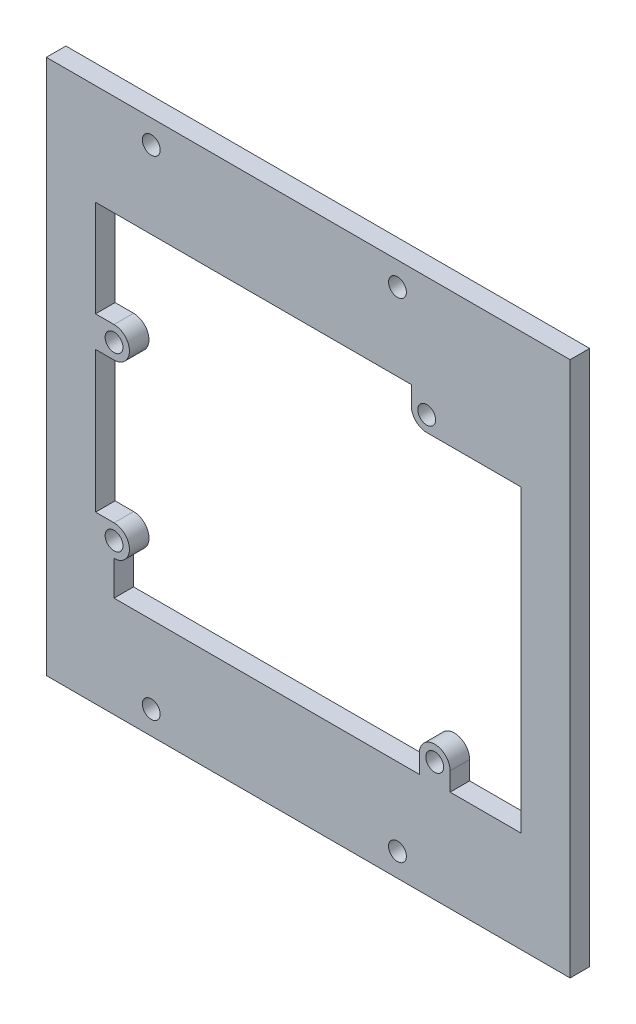
from build123d import *

# Parameters (mm, degrees)
SKETCH1_W           = 85.1
SKETCH1_H           = 87
SKETCH1_R           = 1.45
BOSS_EXTRUDE1_DEPTH = 3.175


with BuildPart() as part:
    # Sketch1 → Boss-Extrude1 (new body)
    with BuildSketch(Plane.XY):
        with Locations((5.5, 0)):
            Rectangle(SKETCH1_W, SKETCH1_H)
        with Locations((-20, 39.6925)):
            Circle(SKETCH1_R, mode=Mode.SUBTRACT)
        with Locations((-20, -39.6925)):
            Circle(SKETCH1_R, mode=Mode.SUBTRACT)
        with Locations((20, -39.6925)):
            Circle(SKETCH1_R, mode=Mode.SUBTRACT)
        with Locations((20, 39.6925)):
            Circle(SKETCH1_R, mode=Mode.SUBTRACT)
        with Locations((-26.05, 8.9)):
            Circle(SKETCH1_R, mode=Mode.SUBTRACT)
        with Locations((-26.05, -19)):
            Circle(SKETCH1_R, mode=Mode.SUBTRACT)
        with Locations((24.75, 24.1)):
            Circle(SKETCH1_R, mode=Mode.SUBTRACT)
        with Locations((26.05, -24.1)):
            Circle(SKETCH1_R, mode=Mode.SUBTRACT)
        with BuildLine():
            Line((-26.05, 6.4), (-29.05, 6.4))
            Line((-29.05, 6.4), (-29.05, -16.5))
            Line((-29.05, -16.5), (-26.05, -16.5))
            ThreePointArc((-26.05, -16.5), (-23.55, -19), (-26.05, -21.5))
            Line((-26.05, -21.5), (-26.05, -27.1))
            Line((-26.05, -27.1), (23.55, -27.1))
            Line((23.55, -27.1), (23.55, -24.1))
            ThreePointArc((23.55, -24.1), (26.05, -21.6), (28.55, -24.1))
            Line((28.55, -24.1), (28.55, -27.1))
            Line((28.55, -27.1), (40.05, -27.1))
            Line((40.05, -27.1), (40.05, 21.6))
            Line((40.05, 21.6), (24.75, 21.6))
            ThreePointArc((24.75, 21.6), (22.982233047, 22.332233047), (22.25, 24.1))
            Line((22.25, 24.1), (22.25, 27.1))
            Line((22.25, 27.1), (-29.05, 27.1))
            Line((-29.05, 27.1), (-29.05, 11.4))
            Line((-29.05, 11.4), (-26.05, 11.4))
            ThreePointArc((-26.05, 11.4), (-23.55, 8.9), (-26.05, 6.4))
        make_face(mode=Mode.SUBTRACT)
    extrude(amount=BOSS_EXTRUDE1_DEPTH)


solid = part.part
